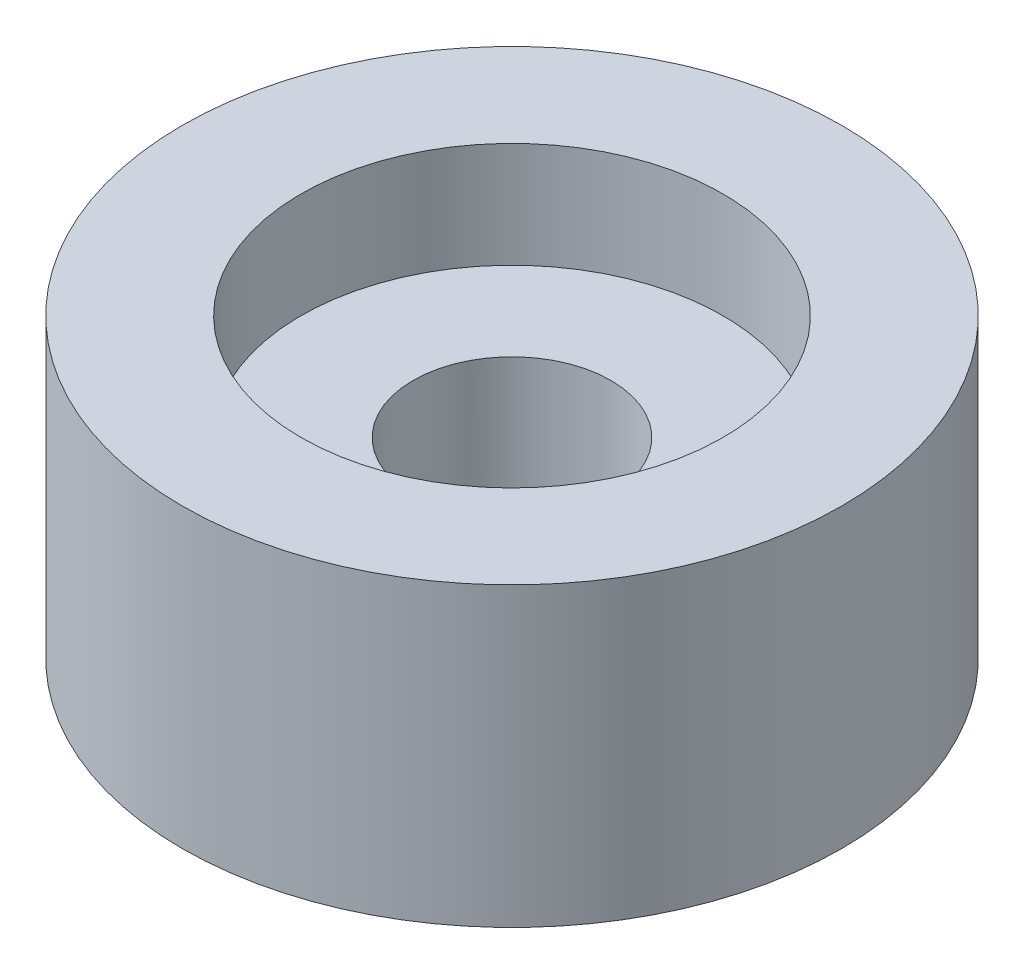
from build123d import *

# Parameters (mm, degrees)
SKETCH1_W          = 7
SKETCH1_H          = 9
SKETCH2_R          = 6.4
CUT_EXTRUDE1_DEPTH = 3.2


with BuildPart() as part:
    # Sketch1 → Revolve1 (revolve)
    with BuildSketch(Plane.XY):
        with Locations((6.5, 4.5)):
            Rectangle(SKETCH1_W, SKETCH1_H)
    revolve(axis=Axis((0, 0, 0), (0, 1, 0)))

    # Sketch2 → Cut-Extrude1 (cut)
    with BuildSketch(Plane(origin=(0, 9, 0), x_dir=(1, 0, 0), z_dir=(0, 1, 0))):
        Circle(SKETCH2_R)
    extrude(amount=-CUT_EXTRUDE1_DEPTH, mode=Mode.SUBTRACT)


solid = part.part
